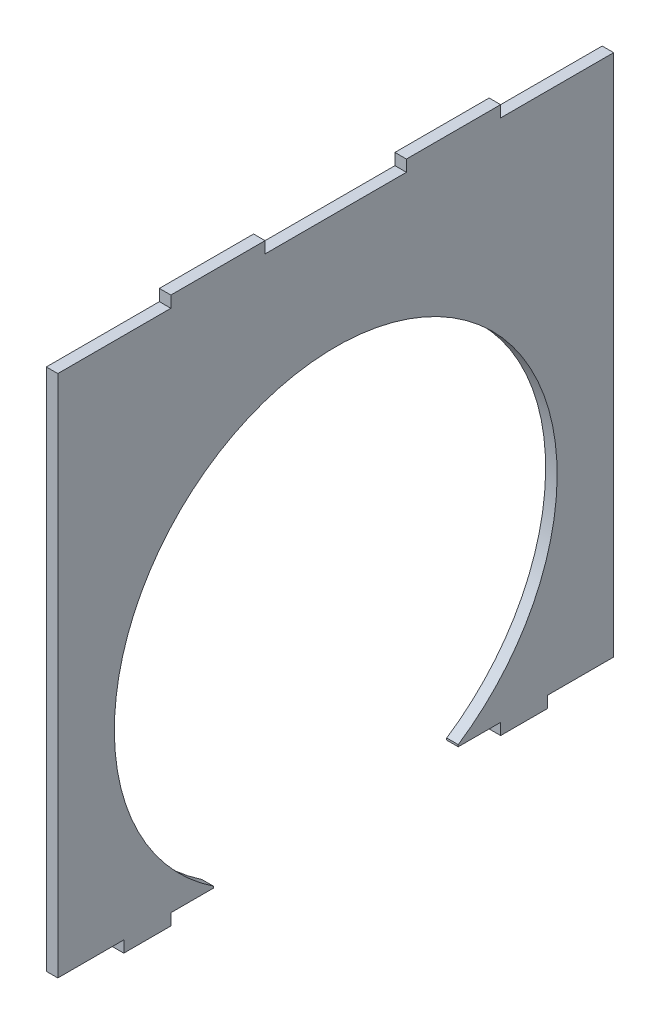
from build123d import *

# Parameters (mm, degrees)
SALIENTE_EXTRUIR1_DEPTH = 2.44


with BuildPart() as part:
    # Croquis1 → Saliente-Extruir1 (new body)
    with BuildSketch(Plane(origin=(0, 0, 0), x_dir=(0, 0, -1), z_dir=(1, 0, 0))):
        with BuildLine():
            Line((26, -55.56), (26, -55.153543901))
            ThreePointArc((26, -55.153543901), (0, 31), (-26, -55.153543901))
            Line((-26, -55.153543901), (-26, -55.56))
            Line((-26, -55.56), (-35, -55.56))
            Line((-35, -55.56), (-35, -58))
            Line((-35, -58), (-45, -58))
            Line((-45, -58), (-45, -55.56))
            Line((-45, -55.56), (-59, -55.56))
            Line((-59, -55.56), (-59, 55.56))
            Line((-59, 55.56), (-35, 55.56))
            Line((-35, 55.56), (-35, 58))
            Line((-35, 58), (-15, 58))
            Line((-15, 58), (-15, 55.56))
            Line((-15, 55.56), (15, 55.56))
            Line((15, 55.56), (15, 58))
            Line((15, 58), (35, 58))
            Line((35, 58), (35, 55.56))
            Line((35, 55.56), (59, 55.56))
            Line((59, 55.56), (59, -55.56))
            Line((59, -55.56), (45, -55.56))
            Line((45, -55.56), (45, -58))
            Line((45, -58), (35, -58))
            Line((35, -58), (35, -55.56))
            Line((35, -55.56), (26, -55.56))
        make_face()
    extrude(amount=SALIENTE_EXTRUIR1_DEPTH)


solid = part.part
